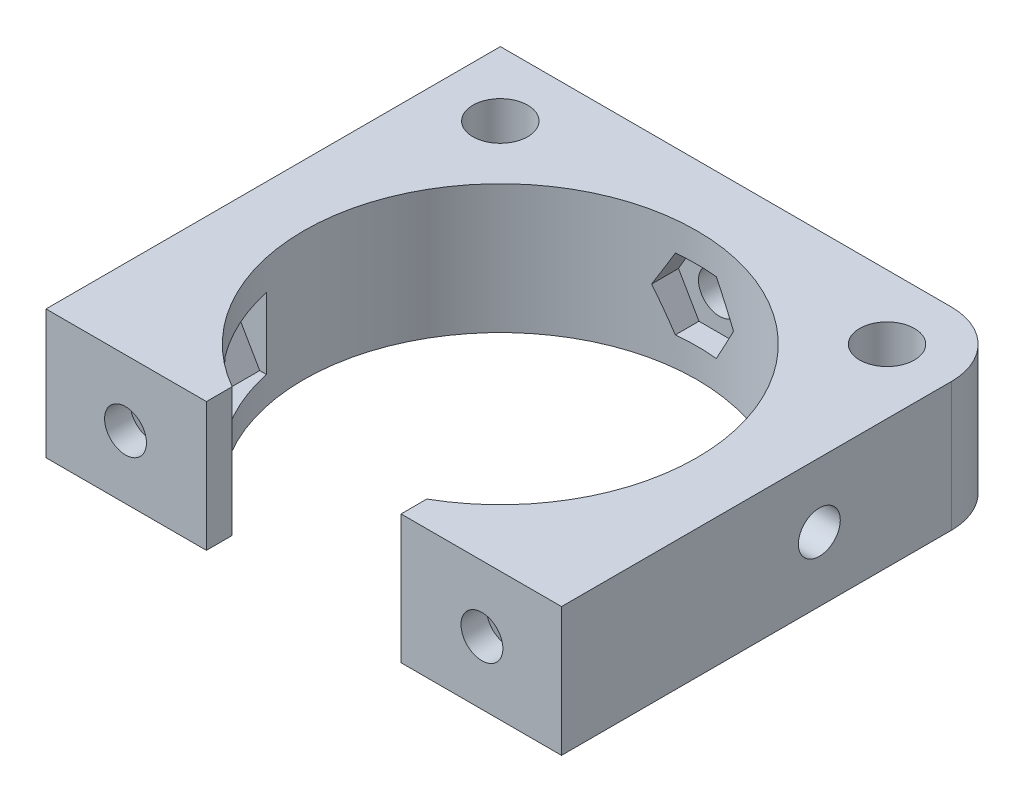
from build123d import *

# Parameters (mm, degrees)
CROQUIS1_R                              = 15.25
CROQUIS1_R_2                            = 2.125
SOPORTE_CAJA_REDUCTORA_DEPTH            = 20
CROQUIS3_R                              = 2.125
CORTAR_EXTRUIR1_DEPTH                   = 51.423828692
REDONDEO1_R                             = 5
BOSS_EXTRUDE1_DEPTH                     = 20
CUT_EXTRUDE1_REACH                      = 55.852
SKETCH2_R                               = 1.625
CUT_EXTRUDE2_DEPTH                      = 2
SKETCH4_R                               = 1.625
CUT_EXTRUDE3_DEPTH                      = 63.291652731
CUT_EXTRUDE4_START                      = -4.5
CUT_EXTRUDE4_DEPTH                      = 2
CROQUIS6_W                              = 4.75
CROQUIS6_H                              = 4.75
CORTAR_EXTRUIR17_DEPTH                  = 42.231056256
CROQUIS7_W                              = 60
CROQUIS7_H                              = 20
CORTAR_EXTRUIR18_DEPTH                  = 51.423828692
SALIENTE_EXTRUIR2_DEPTH                 = 49
SOPORTE_START                           = -15
SOPORTE_MOTOR_DEPTH                     = 15
CROQUIS12_R                             = 2.125
AGUJEROS_DE_SUJECION_A_BASE_DEPTH       = 84.087679592
TUERCA_START                            = -4
TUERCA_AGUJERO_DE_SUJECION_A_BASE_DEPTH = 10
SALIENTE_EXTRUIR4_DEPTH                 = 15
CORTAR_EXTRUIR19_DEPTH                  = 25
CROQUIS14_W                             = 50
CROQUIS14_H                             = 118
CORTAR_EXTRUIR22_DEPTH                  = 146.556045907
CROQUIS15_W                             = 10
CROQUIS15_H                             = 7
CORTAR_EXTRUIR23_DEPTH                  = 42.231056256
CORTAR_EXTRUIR24_DEPTH                  = 42.231056256
CROQUIS18_W                             = 40
CROQUIS18_H                             = 10
CORTAR_EXTRUIR25_DEPTH                  = 44.27311521
SALIENTE_EXTRUIR5_DEPTH                 = 10
CROQUIS20_R                             = 1
CORTAR_EXTRUIR26_DEPTH                  = 49.229270158
CORTAR_EXTRUIR27_REACH                  = 62.959
CORTAR_EXTRUIR27_END_RADIUS             = 15.25
CROQUIS21_R                             = 1.625
CROQUIS22_R                             = 2.125
CROQUIS22_R_2                           = 1
SALIENTE_EXTRUIR6_DEPTH                 = 10
CROQUIS23_R                             = 1.625
CORTAR_EXTRUIR28_DEPTH                  = 52.269508521
CORTAR_EXTRUIR29_START                  = -3
CORTAR_EXTRUIR29_DEPTH                  = 10
SALIENTE_EXTRUIR7_DEPTH                 = 10
CORTAR_EXTRUIR30_REACH                  = 72.235
CROQUIS27_R                             = 1.625
CORTAR_EXTRUIR31_REACH                  = 75.235
CORTAR_EXTRUIR31_START                  = -3
CORTAR_EXTRUIR32_REACH                  = 58.612
CROQUIS29_R                             = 1.625
CORTAR_EXTRUIR33_REACH                  = 61.112
CORTAR_EXTRUIR33_START                  = -2.5
CROQUIS35_W                             = 13.305418987
CROQUIS35_H                             = 6.826864192
CORTAR_EXTRUIR34_DEPTH                  = 63.931555098
CORTAR_EXTRUIR34_DEPTH_BACK             = 63.931555098
CORTAR_EXTRUIR35_START                  = -3
CORTAR_EXTRUIR35_DEPTH                  = 10
SALIENTE_EXTRUIR8_DEPTH                 = 10
SALIENTE_EXTRUIR9_DEPTH                 = 13
SALIENTE_EXTRUIR10_DEPTH                = 3
CROQUIS40_W                             = 106.583537839
CROQUIS40_H                             = 47.391515964
CORTAR_EXTRUIR36_DEPTH                  = 80.887064817
CORTAR_EXTRUIR36_DEPTH_BACK             = 80.887064817
CORTAR_EXTRUIR37_DEPTH                  = 67.2524009
CORTAR_EXTRUIR37_DEPTH_BACK             = 67.2524009
CORTAR_EXTRUIR38_DEPTH                  = 79.704784639
CORTAR_EXTRUIR38_DEPTH_BACK             = 79.704784639
SALIENTE_EXTRUIR11_DEPTH                = 10
CORTAR_EXTRUIR39_DEPTH                  = 63.9908649
CROQUIS45_W                             = 31.470301378
CROQUIS45_H                             = 10
CROQUIS45_R                             = 1.625
SALIENTE_EXTRUIR12_DEPTH                = 2.5
SALIENTE_EXTRUIR13_DEPTH                = 10
CORTAR_EXTRUIR40_START                  = -2
CROQUIS47_R                             = 1.625
CORTAR_EXTRUIR40_DEPTH                  = 10
CORTAR_EXTRUIR41_START                  = -12
CROQUIS48_R                             = 1.625
CORTAR_EXTRUIR41_DEPTH                  = 12
CORTAR_EXTRUIR42_DEPTH                  = 3
CROQUIS50_W                             = 80.415439526
CROQUIS50_H                             = 16.145703155
CORTAR_EXTRUIR43_DEPTH                  = 66.767385996
CORTAR_EXTRUIR43_DEPTH_BACK             = 66.767385996
CROQUIS51_R                             = 2.125
CORTAR_EXTRUIR44_DEPTH                  = 52.795622989
CORTAR_EXTRUIR44_DEPTH_BACK             = 52.795622989
CORTAR_EXTRUIR45_DEPTH                  = 52.795622989
CORTAR_EXTRUIR45_DEPTH_BACK             = 52.795622989
SALIENTE_EXTRUIR14_DEPTH                = 10
CORTAR_EXTRUIR46_START                  = -24.591895
CORTAR_EXTRUIR46_DEPTH                  = 17.091895
CROQUIS55_W                             = 24.668528906
CROQUIS55_H                             = 42.621944376
CORTAR_EXTRUIR47_DEPTH                  = 42.681058385
CORTAR_EXTRUIR47_DEPTH_BACK             = 42.681058385


with BuildPart() as part:
    # Croquis1 → Soporte caja reductora (new body)
    with BuildSketch(Plane(origin=(0, 0, 0), x_dir=(1, 0, 0), z_dir=(0, 1, 0))):
        Polygon((-30, -15.25), (-20, -15.25), (-20, -20), (20, -20), (20, -15.25), (30, -15.25), (30, -7.25), (20, -4.25), (20, 20), (-20, 20), (-20, -4.25), (-30, -7.25), align=None)
        with Locations(Location((0, 0, 0), (0, 0, 270))):
            Circle(CROQUIS1_R, mode=Mode.SUBTRACT)
        with Locations(Location((-15, 15, 0), (0, 0, 270))):
            Circle(CROQUIS1_R_2, mode=Mode.SUBTRACT)
        with Locations(Location((15, 15, 0), (0, 0, 270))):
            Circle(CROQUIS1_R_2, mode=Mode.SUBTRACT)
    extrude(amount=-SOPORTE_CAJA_REDUCTORA_DEPTH)

    # Croquis3 → Cortar-Extruir1 (cut, through all)
    with BuildSketch(Plane.XY.offset(15.25)):
        with Locations((-23.5, -10)):
            Circle(CROQUIS3_R)
        with Locations((23.5, -10)):
            Circle(CROQUIS3_R)
    extrude(amount=-CORTAR_EXTRUIR1_DEPTH, mode=Mode.SUBTRACT)

    # Redondeo1
    redondeo1_edges = [part.edges().sort_by_distance(p)[0] for p in [
        (-20, -10, -20),
        (20, -10, -20),
    ]]
    fillet(redondeo1_edges, radius=REDONDEO1_R)

    # Sketch1 → Boss-Extrude1 (add)
    with BuildSketch(Plane(origin=(0, 0, 0), x_dir=(1, 0, 0), z_dir=(0, 1, 0))):
        with BuildLine():
            Line((25.5, 15), (20, 15))
            ThreePointArc((20, 15), (18.535533906, 18.535533906), (15, 20))
            Line((15, 20), (30, 20))
            Line((30, 20), (30, 8))
            Line((30, 8), (25.5, 8))
            Line((25.5, 8), (25.5, 15))
        make_face()
    extrude(amount=-BOSS_EXTRUDE1_DEPTH)

    # Sketch2 → Cut-Extrude1 (cut, up to next)
    with BuildSketch(Plane(origin=(0, 0, -20), x_dir=(-1, 0, 0), z_dir=(0, 0, -1)), mode=Mode.PRIVATE) as cut_extrude1_sk1:
        with Locations((-22.75, -10)):
            Circle(SKETCH2_R)
    cut_extrude1_tool1 = extrude(cut_extrude1_sk1.sketch, amount=-CUT_EXTRUDE1_REACH, mode=Mode.PRIVATE) & part.part
    add(cut_extrude1_tool1.solids().sort_by_distance((22.75, -10, -20))[0], mode=Mode.SUBTRACT)

    # Sketch3 → Cut-Extrude2 (cut)
    with BuildSketch(Plane.XY.offset(-15)):
        Polygon((20, -11.58771324), (22.75, -13.175426481), (25.5, -11.58771324), (25.5, -8.41228676), (22.75, -6.824573519), (20, -8.41228676), align=None)
    extrude(amount=-CUT_EXTRUDE2_DEPTH, mode=Mode.SUBTRACT)

    # Sketch4 → Cut-Extrude3 (cut, through all)
    with BuildSketch(Plane.ZY.offset(-25.5)):
        with Locations((-12.25, -10)):
            Circle(SKETCH4_R)
    extrude(amount=-CUT_EXTRUDE3_DEPTH, mode=Mode.SUBTRACT)

    # Sketch5 → Cut-Extrude4 (cut)
    with BuildSketch(Plane(origin=(30, 0, 0), x_dir=(0, 0, -1), z_dir=(1, 0, 0)).offset(CUT_EXTRUDE4_START)):
        Polygon((15, -11.58771324), (15, -8.41228676), (12.25, -6.824573519), (9.5, -8.41228676), (9.5, -11.58771324), (12.25, -13.175426481), align=None)
    extrude(amount=CUT_EXTRUDE4_DEPTH, mode=Mode.SUBTRACT)

    # Croquis6 → Cortar-Extruir17 (cut, through all)
    with BuildSketch(Plane(origin=(0, 0, 0), x_dir=(1, 0, 0), z_dir=(0, 1, 0))):
        Polygon((0, -15.25), (-15.25, -15.25), (-15.25, -20), (15.25, -20), (15.25, -15.25), align=None)
        with Locations((-17.625, -17.625)):
            Rectangle(CROQUIS6_W, CROQUIS6_H)
        with BuildLine():
            ThreePointArc((0, -15.25), (-10.783378413, -10.783378413), (-15.25, 0))
            Line((-15.25, 0), (-15.25, -15.25))
            Line((-15.25, -15.25), (0, -15.25))
        make_face()
        with BuildLine():
            Line((15.25, -15.25), (15.25, 0))
            ThreePointArc((15.25, 0), (10.783378413, -10.783378413), (0, -15.25))
            Line((0, -15.25), (15.25, -15.25))
        make_face()
        with Locations((17.625, -17.625)):
            Rectangle(CROQUIS6_W, CROQUIS6_H)
    extrude(amount=-CORTAR_EXTRUIR17_DEPTH, mode=Mode.SUBTRACT)


with BuildPart() as body_2:
    # Simetría1: mirrored copy
    add(part.part.mirror(Plane.ZX))

    # Croquis8 → Saliente-Extruir2 (add)
    with BuildSketch(Plane(origin=(0, 20, 0), x_dir=(1, 0, 0), z_dir=(0, 1, 0))):
        with BuildLine():
            Line((-12.664515522, 20), (-11.040489496, 13.939052358))
            Line((-11.040489496, 13.939052358), (-10.315162126, 11.232093763))
            ThreePointArc((-10.315162126, 11.232093763), (0, 15.25), (10.315162126, 11.232093763))
            Line((10.315162126, 11.232093763), (10.817418481, 13.87928066))
            Line((10.817418481, 13.87928066), (11.978715476, 20))
            Line((11.978715476, 20), (-12.664515522, 20))
        make_face()
    extrude(amount=SALIENTE_EXTRUIR2_DEPTH)

    # Croquis9 → Soporte motor (add)
    with BuildSketch(Plane(origin=(0, 69, 0), x_dir=(1, 0, 0), z_dir=(0, 1, 0)).offset(SOPORTE_START)):
        with BuildLine():
            Line((-20, 15), (-20, -4.25))
            Line((-20, -4.25), (-30, -7.25))
            Line((-30, -7.25), (-30, -15.25))
            Line((-30, -15.25), (0, -15.25))
            Line((0, -15.25), (0, -14.75))
            ThreePointArc((0, -14.75), (-10.429825023, 10.429825023), (14.75, 0))
            Line((14.75, 0), (20, 0))
            Line((20, 0), (20, 13.936837101))
            Line((20, 13.936837101), (12.664515522, 20))
            Line((12.664515522, 20), (-15, 20))
            ThreePointArc((-15, 20), (-18.535533906, 18.535533906), (-20, 15))
        make_face()
    extrude(amount=-SOPORTE_MOTOR_DEPTH)

    # Croquis12 → Agujeros de sujecion a base (cut, through all)
    with BuildSketch(Plane.XY.offset(15.25)):
        with Locations((-23.5, 46.5)):
            Circle(CROQUIS12_R)
    extrude(amount=-AGUJEROS_DE_SUJECION_A_BASE_DEPTH, mode=Mode.SUBTRACT)

    # Croquis13 → Tuerca Agujero de sujecion a base (cut)
    with BuildSketch(Plane.XY.offset(15.25).offset(TUERCA_START)):
        Polygon((-20, 44.479274058), (-20, 48.520725942), (-23.5, 50.541451884), (-27, 48.520725942), (-27, 44.479274058), (-23.5, 42.458548116), align=None)
    extrude(amount=-TUERCA_AGUJERO_DE_SUJECION_A_BASE_DEPTH, mode=Mode.SUBTRACT)

    # Croquis10 → Saliente-Extruir4 (add)
    with BuildSketch(Plane(origin=(0, 69, 0), x_dir=(1, 0, 0), z_dir=(0, 1, 0))):
        with BuildLine():
            ThreePointArc((10.315162126, 11.232093763), (0, 15.25), (-10.315162126, 11.232093763))
            Line((-10.315162126, 11.232093763), (-10.16850369, 10.684757026))
            ThreePointArc((-10.16850369, 10.684757026), (0, 14.75), (10.16850369, 10.684757026))
            Line((10.16850369, 10.684757026), (10.315162126, 11.232093763))
        make_face()
    extrude(amount=-SALIENTE_EXTRUIR4_DEPTH)

    # Croquis11 → Cortar-Extruir19 (cut)
    with BuildSketch(Plane.XZ):
        with BuildLine():
            Line((15.25, 4.25), (20, 4.25))
            Line((20, 4.25), (21.972856468, 4.84185694))
            ThreePointArc((21.972856468, 4.84185694), (19.948931102, 10.40625523), (16.543503257, 15.25))
            Line((16.543503257, 15.25), (15.25, 15.25))
            Line((15.25, 15.25), (15.25, 4.25))
        make_face()
        with BuildLine():
            Line((21.972856468, 4.84185694), (30, 7.25))
            Line((30, 7.25), (30, 15.25))
            Line((30, 15.25), (16.543503257, 15.25))
            ThreePointArc((16.543503257, 15.25), (19.948931102, 10.40625523), (21.972856468, 4.84185694))
        make_face()
        with BuildLine():
            ThreePointArc((20, -15), (18.535533906, -18.535533906), (15, -20))
            Line((15, -20), (30, -20))
            Line((30, -20), (30, -8))
            Line((30, -8), (25.5, -8))
            Line((25.5, -8), (25.5, -15))
            Line((25.5, -15), (20, -15))
        make_face()
    extrude(amount=-CORTAR_EXTRUIR19_DEPTH, mode=Mode.SUBTRACT)

    # Simetría2: body 2 across face


with BuildPart() as part_1:
    add(part.part)

    # Croquis7 → Cortar-Extruir18 (cut, through all)
    with BuildSketch(Plane(origin=(0, 0, -20), x_dir=(-1, 0, 0), z_dir=(0, 0, -1))):
        with Locations((0, -10)):
            Rectangle(CROQUIS7_W, CROQUIS7_H)
    extrude(amount=-CORTAR_EXTRUIR18_DEPTH, mode=Mode.SUBTRACT)


with BuildPart() as body_2_1:
    add(body_2.part)
    add(body_2.part.mirror(Plane(origin=(-0.229209569, 69, -16.663998028), x_dir=(0, 0, 1), z_dir=(0, 1, 0))))

    # Croquis14 → Cortar-Extruir22 (cut, through all)
    with BuildSketch(Plane.XY.offset(15.25)):
        with Locations((-5, 79)):
            Rectangle(CROQUIS14_W, CROQUIS14_H)
    extrude(amount=-CORTAR_EXTRUIR22_DEPTH, mode=Mode.SUBTRACT)

    # Croquis15 → Cortar-Extruir23 (cut, through all)
    with BuildSketch(Plane.XZ):
        with Locations((-25, 7.75)):
            Rectangle(CROQUIS15_W, CROQUIS15_H)
    extrude(amount=-CORTAR_EXTRUIR23_DEPTH, mode=Mode.SUBTRACT)

    # Croquis16 → Cortar-Extruir24 (cut, through all)
    with BuildSketch(Plane.XZ):
        Polygon((-30, 15.25), (-15.25, 15.25), (-15.25, 12.75), (-20, 12.75), (-20, 11.25), (-30, 11.25), (-30, 12.75), align=None)
    extrude(amount=-CORTAR_EXTRUIR24_DEPTH, mode=Mode.SUBTRACT)

    # Croquis18 → Cortar-Extruir25 (cut, through all)
    with BuildSketch(Plane(origin=(0, 0, -20), x_dir=(-1, 0, 0), z_dir=(0, 0, -1))):
        with Locations((0, 5)):
            Rectangle(CROQUIS18_W, CROQUIS18_H)
    extrude(amount=-CORTAR_EXTRUIR25_DEPTH, mode=Mode.SUBTRACT)

    # Croquis19 → Saliente-Extruir5 (add)
    with BuildSketch(Plane(origin=(0, 20, 0), x_dir=(1, 0, 0), z_dir=(0, 1, 0))):
        Polygon((-20, -12.75), (-34, -12.75), (-34, -7.75), (-24, -7.75), (-20, -3.75), align=None)
    extrude(amount=-SALIENTE_EXTRUIR5_DEPTH)

    # Croquis20 → Cortar-Extruir26 (cut, through all)
    with BuildSketch(Plane(origin=(0, 0, 7.75), x_dir=(-1, 0, 0), z_dir=(0, 0, -1))):
        with Locations((29, 15)):
            Circle(CROQUIS20_R)
    extrude(amount=-CORTAR_EXTRUIR26_DEPTH, mode=Mode.SUBTRACT)

    # Cortar-Extruir27: up to this cylinder (the profile starts outside it)
    cortar_extruir27_end = Plane(origin=(0, 15, 0), z_dir=(0, -1, 0)) * Cylinder(CORTAR_EXTRUIR27_END_RADIUS, 157.418, mode=Mode.PRIVATE)
    # Croquis21 → Cortar-Extruir27 (cut, up to the surface)
    with BuildSketch(Plane(origin=(20, 0, 0), x_dir=(0, 0, -1), z_dir=(1, 0, 0)), mode=Mode.PRIVATE) as cortar_extruir27_sk1:
        with Locations((4.75, 15)):
            Circle(CROQUIS21_R)
    cortar_extruir27_tool1 = extrude(cortar_extruir27_sk1.sketch, amount=-CORTAR_EXTRUIR27_REACH, mode=Mode.PRIVATE) - cortar_extruir27_end
    add(cortar_extruir27_tool1.solids().sort_by_distance((20, 15, -4.75))[0], mode=Mode.SUBTRACT)

    # Croquis22 → Saliente-Extruir6 (add)
    with BuildSketch(Plane.XZ.offset(-10)):
        with Locations((-15, -15)):
            Circle(CROQUIS22_R)
        with Locations(Location((-15, -15, 0), (0, 0, 270))):
            Circle(CROQUIS22_R_2, mode=Mode.SUBTRACT)
        with Locations((15, -15)):
            Circle(CROQUIS22_R)
        with Locations(Location((15, -15, 0), (0, 0, 270))):
            Circle(CROQUIS22_R_2, mode=Mode.SUBTRACT)
    extrude(amount=-SALIENTE_EXTRUIR6_DEPTH)

    # Croquis23 → Cortar-Extruir28 (cut, through all)
    with BuildSketch(Plane(origin=(0, 0, -20), x_dir=(-1, 0, 0), z_dir=(0, 0, -1))):
        with Locations((0, 15)):
            Circle(CROQUIS23_R)
    extrude(amount=-CORTAR_EXTRUIR28_DEPTH, mode=Mode.SUBTRACT)

    # Croquis24 → Cortar-Extruir29 (cut)
    with BuildSketch(Plane(origin=(0, 0, -20), x_dir=(-1, 0, 0), z_dir=(0, 0, -1)).offset(CORTAR_EXTRUIR29_START)):
        Polygon((1.58771324, 12.25), (3.175426481, 15), (1.58771324, 17.75), (-1.58771324, 17.75), (-3.175426481, 15), (-1.58771324, 12.25), align=None)
    extrude(amount=-CORTAR_EXTRUIR29_DEPTH, mode=Mode.SUBTRACT)

    # Croquis26 → Saliente-Extruir7 (add)
    with BuildSketch(Plane.XZ.offset(-10)):
        Polygon((-34, 7.75), (-34, 12.75), (-58.825, 12.75), (-39.160527763, -4.104491148), (-20, -4.104491148), (-20, -0.104491148), (-35.732113118, -0.104491148), (-29, 7.75), align=None)
        Polygon((-34.268209086, 7.75), (-39.594516123, 1.535690951), (-46.844874897, 7.75), align=None, mode=Mode.SUBTRACT)
    extrude(amount=-SALIENTE_EXTRUIR7_DEPTH)

    # Croquis27 → Cortar-Extruir30 (cut, up to next)
    with BuildSketch(Plane.XY.offset(12.75), mode=Mode.PRIVATE) as cortar_extruir30_sk1:
        with Locations((-40.544874897, 15)):
            Circle(CROQUIS27_R)
    cortar_extruir30_tool1 = extrude(cortar_extruir30_sk1.sketch, amount=-CORTAR_EXTRUIR30_REACH, mode=Mode.PRIVATE) & body_2_1.part
    # Croquis27 → Cortar-Extruir30 (cut, up to next)
    with BuildSketch(Plane.XY.offset(12.75), mode=Mode.PRIVATE) as cortar_extruir30_sk2:
        with Locations((-29, 15)):
            Circle(CROQUIS27_R)
    cortar_extruir30_tool2 = extrude(cortar_extruir30_sk2.sketch, amount=-CORTAR_EXTRUIR30_REACH, mode=Mode.PRIVATE) & body_2_1.part
    add(cortar_extruir30_tool1.solids().sort_by_distance((-40.544875, 15, 12.75))[0], mode=Mode.SUBTRACT)
    add(cortar_extruir30_tool2.solids().sort_by_distance((-29, 15, 12.75))[0], mode=Mode.SUBTRACT)

    # Croquis28 → Cortar-Extruir31 (cut, up to next)
    with BuildSketch(Plane.XY.offset(12.75).offset(CORTAR_EXTRUIR31_START), mode=Mode.PRIVATE) as cortar_extruir31_sk1:
        Polygon((-38.957161657, 12.25), (-37.369448416, 15), (-38.957161657, 17.75), (-42.132588137, 17.75), (-43.720301378, 15), (-42.132588137, 12.25), align=None)
    cortar_extruir31_tool1 = extrude(cortar_extruir31_sk1.sketch, amount=-CORTAR_EXTRUIR31_REACH, mode=Mode.PRIVATE) & body_2_1.part
    # Croquis28 → Cortar-Extruir31 (cut, up to next)
    with BuildSketch(Plane.XY.offset(12.75).offset(CORTAR_EXTRUIR31_START), mode=Mode.PRIVATE) as cortar_extruir31_sk2:
        Polygon((-27.41228676, 12.25), (-25.824573519, 15), (-27.41228676, 17.75), (-30.58771324, 17.75), (-32.175426481, 15), (-30.58771324, 12.25), align=None)
    cortar_extruir31_tool2 = extrude(cortar_extruir31_sk2.sketch, amount=-CORTAR_EXTRUIR31_REACH, mode=Mode.PRIVATE) & body_2_1.part
    add(cortar_extruir31_tool1.solids().sort_by_distance((-40.544875, 15, 9.75))[0], mode=Mode.SUBTRACT)
    add(cortar_extruir31_tool2.solids().sort_by_distance((-29, 15, 9.75))[0], mode=Mode.SUBTRACT)

    # Croquis29 → Cortar-Extruir32 (cut, up to next)
    with BuildSketch(Plane(origin=(-18.612848159, 0, -21.715982563), x_dir=(-0.7592713073348843, 0, 0.6507742172658468), z_dir=(-0.6507742172658468, 0, -0.7592713073348843)), mode=Mode.PRIVATE) as cortar_extruir32_sk1:
        with Locations((33.812368097, 15)):
            Circle(CROQUIS29_R)
    cortar_extruir32_tool1 = extrude(cortar_extruir32_sk1.sketch, amount=-CORTAR_EXTRUIR32_REACH, mode=Mode.PRIVATE) & body_2_1.part
    add(cortar_extruir32_tool1.solids().sort_by_distance((-44.285609, 15, 0.288235))[0], mode=Mode.SUBTRACT)

    # Croquis31 → Cortar-Extruir33 (cut, up to next)
    with BuildSketch(Plane(origin=(-18.612848159, 0, -21.715982563), x_dir=(-0.7592713073348843, 0, 0.6507742172658468), z_dir=(-0.6507742172658468, 0, -0.7592713073348843)).offset(CORTAR_EXTRUIR33_START), mode=Mode.PRIVATE) as cortar_extruir33_sk1:
        Polygon((36.562368097, 16.58771324), (33.812368097, 18.175426481), (31.062368097, 16.58771324), (31.062368097, 13.41228676), (33.812368097, 11.824573519), (36.562368097, 13.41228676), align=None)
    cortar_extruir33_tool1 = extrude(cortar_extruir33_sk1.sketch, amount=-CORTAR_EXTRUIR33_REACH, mode=Mode.PRIVATE) & body_2_1.part
    add(cortar_extruir33_tool1.solids().sort_by_distance((-42.658674, 15, 2.186413))[0], mode=Mode.SUBTRACT)

    # Croquis35 → Cortar-Extruir34 (cut, two sides)
    with BuildSketch(Plane(origin=(0, 20, 0), x_dir=(1, 0, 0), z_dir=(0, 1, 0))) as cortar_extruir34_sk:
        with Locations((17.04227466, -3.413432096)):
            Rectangle(CROQUIS35_W, CROQUIS35_H)
    extrude(amount=CORTAR_EXTRUIR34_DEPTH, mode=Mode.SUBTRACT)
    extrude(cortar_extruir34_sk.sketch, amount=-CORTAR_EXTRUIR34_DEPTH_BACK, mode=Mode.SUBTRACT)

    # Croquis36 → Cortar-Extruir35 (cut)
    with BuildSketch(Plane(origin=(20, 0, 0), x_dir=(0, 0, -1), z_dir=(1, 0, 0)).offset(CORTAR_EXTRUIR35_START)):
        Polygon((7.5, 16.58771324), (4.75, 18.175426481), (2, 16.58771324), (2, 13.41228676), (4.75, 11.824573519), (7.5, 13.41228676), align=None)
    extrude(amount=-CORTAR_EXTRUIR35_DEPTH, mode=Mode.SUBTRACT)

    # Croquis37 → Saliente-Extruir8 (add)
    with BuildSketch(Plane.XZ.offset(-10)):
        Polygon((-39.160527763, -4.104491148), (-20.614919368, -20), (-15, -20), (-19.558128305, -15.637570403), (-33.014002756, -4.104491148), align=None)
    extrude(amount=-SALIENTE_EXTRUIR8_DEPTH)

    # Croquis38 → Saliente-Extruir9 (add)
    with BuildSketch(Plane.XZ.offset(-10)):
        Polygon((-58.825, 12.75), (-38.825, 12.75), (-38.825, 9.75), (-55.324839942, 9.75), align=None)
    extrude(amount=SALIENTE_EXTRUIR9_DEPTH)

    # Croquis39 → Saliente-Extruir10 (add)
    with BuildSketch(Plane.XZ.offset(-10)):
        Polygon((-38.825, 9.75), (-38.825, 7.75), (-38.825, 5.75), (-50.657959865, 5.75), (-52.991399903, 7.75), (-55.324839942, 9.75), align=None)
    extrude(amount=SALIENTE_EXTRUIR10_DEPTH)

    # Simetría3: body 2 across face


with BuildPart() as body_2_2:
    add(body_2_1.part)
    add(body_2_1.part.mirror(Plane(origin=(-18.003999227, 20, -4.220503046), x_dir=(0, 0, 1), z_dir=(0, 1, 0))))

    # Croquis40 → Cortar-Extruir36 (cut, two sides)
    with BuildSketch(Plane(origin=(0, 0, -20), x_dir=(-1, 0, 0), z_dir=(0, 0, -1))) as cortar_extruir36_sk:
        with Locations((22.395502026, -3.695757982)):
            Rectangle(CROQUIS40_W, CROQUIS40_H)
    extrude(amount=CORTAR_EXTRUIR36_DEPTH, mode=Mode.SUBTRACT)
    extrude(cortar_extruir36_sk.sketch, amount=-CORTAR_EXTRUIR36_DEPTH_BACK, mode=Mode.SUBTRACT)

    # Croquis41 → Cortar-Extruir37 (cut, two sides)
    with BuildSketch(Plane.XZ.offset(-20)) as cortar_extruir37_sk:
        Polygon((-19.992980133, -22.302484261), (-20, 3.75), (-24, 7.75), (-56.035110209, 7.75), align=None)
    extrude(amount=CORTAR_EXTRUIR37_DEPTH, mode=Mode.SUBTRACT)
    extrude(cortar_extruir37_sk.sketch, amount=-CORTAR_EXTRUIR37_DEPTH_BACK, mode=Mode.SUBTRACT)

    # Croquis42 → Cortar-Extruir38 (cut, two sides)
    with BuildSketch(Plane(origin=(0, 0, 9.75), x_dir=(-1, 0, 0), z_dir=(0, 0, -1))) as cortar_extruir38_sk:
        Polygon((46.720301378, 20), (46.720301378, 30), (38.825, 30), (33.492952769, 43.760628779), (49.525340398, 48.951442806), (67.200390695, 42.512205152), (65.906601328, 20), (51.713995885, 13.864168239), align=None)
    extrude(amount=CORTAR_EXTRUIR38_DEPTH, mode=Mode.SUBTRACT)
    extrude(cortar_extruir38_sk.sketch, amount=-CORTAR_EXTRUIR38_DEPTH_BACK, mode=Mode.SUBTRACT)

    # Croquis43 → Saliente-Extruir11 (add)
    with BuildSketch(Plane.XZ.offset(-20)):
        Polygon((-19.993600539, -20), (-46.720301378, 7.75), (-43.839252857, 10.524807997), (-17.112552018, -17.225192003), align=None)
    extrude(amount=-SALIENTE_EXTRUIR11_DEPTH)

    # Croquis44 → Cortar-Extruir39 (cut, through all)
    with BuildSketch(Plane(origin=(0, 0, 9.75), x_dir=(-1, 0, 0), z_dir=(0, 0, -1))):
        Polygon((38.957161657, 27.75), (37.369448416, 25), (38.957161657, 22.25), (42.132588137, 22.25), (43.720301378, 25), (42.132588137, 27.75), align=None)
    extrude(amount=CORTAR_EXTRUIR39_DEPTH, mode=Mode.SUBTRACT)

    # Croquis45 → Saliente-Extruir12 (add)
    with BuildSketch(Plane.XY.offset(12.75)):
        with Locations((-30.985150689, 25)):
            Rectangle(CROQUIS45_W, CROQUIS45_H)
        with Locations((-40.544874897, 25)):
            Circle(CROQUIS45_R, mode=Mode.SUBTRACT)
        with Locations((-29, 25)):
            Circle(CROQUIS45_R, mode=Mode.SUBTRACT)
    extrude(amount=SALIENTE_EXTRUIR12_DEPTH)

    # Croquis46 → Saliente-Extruir13 (add)
    with BuildSketch(Plane.XZ.offset(-20)):
        with BuildLine():
            Line((15.25, 0), (20, 0))
            Line((20, 0), (20, 15.25))
            Line((20, 15.25), (7.549834435, 15.25))
            Line((7.549834435, 15.25), (7.549834435, 13.25))
            ThreePointArc((7.549834435, 13.25), (13.185171124, 7.662490615), (15.25, 0))
        make_face()
        with BuildLine():
            Line((-15.25, 0), (-15.25, 15.25))
            Line((-15.25, 15.25), (-7.549834435, 15.25))
            Line((-7.549834435, 15.25), (-7.549834435, 13.25))
            ThreePointArc((-7.549834435, 13.25), (-13.185171124, 7.662490615), (-15.25, 0))
        make_face()
    extrude(amount=-SALIENTE_EXTRUIR13_DEPTH)

    # Croquis47 → Cortar-Extruir40 (cut)
    with BuildSketch(Plane.XY.offset(15.25).offset(CORTAR_EXTRUIR40_START)):
        Polygon((15.41228676, 22.352505966), (17, 25.102505966), (15.41228676, 27.852505966), (12.236860279, 27.852505966), (10.649147039, 25.102505966), (12.236860279, 22.352505966), align=None)
        with Locations((13.824573519, 25.102505966)):
            Circle(CROQUIS47_R, mode=Mode.SUBTRACT)
        Polygon((-12.236860279, 22.352505966), (-15.41228676, 22.352505966), (-17, 25.102505966), (-15.41228676, 27.852505966), (-12.236860279, 27.852505966), (-10.649147039, 25.102505966), align=None)
        with Locations(Location((-13.824573519, 25.102505966, 0), (0, 0, 131.421584744))):
            Circle(CROQUIS47_R, mode=Mode.SUBTRACT)
    extrude(amount=-CORTAR_EXTRUIR40_DEPTH, mode=Mode.SUBTRACT)

    # Croquis48 → Cortar-Extruir41 (cut)
    with BuildSketch(Plane.XY.offset(15.25).offset(CORTAR_EXTRUIR41_START)):
        with Locations((13.824573519, 25.102505966)):
            Circle(CROQUIS48_R)
        with Locations((-13.824573519, 25.102505966)):
            Circle(CROQUIS48_R)
    extrude(amount=CORTAR_EXTRUIR41_DEPTH, mode=Mode.SUBTRACT)

    # Croquis49 → Cortar-Extruir42 (cut)
    with BuildSketch(Plane(origin=(0, 30, 0), x_dir=(1, 0, 0), z_dir=(0, 1, 0))):
        Polygon((-12.979274058, 11.5), (-10.958548116, 15), (-12.979274058, 18.5), (-17.020725942, 18.5), (-19.041451884, 15), (-17.020725942, 11.5), align=None)
        Polygon((17.020725942, 11.5), (19.041451884, 15), (17.020725942, 18.5), (12.979274058, 18.5), (10.958548116, 15), (12.979274058, 11.5), align=None)
    extrude(amount=-CORTAR_EXTRUIR42_DEPTH, mode=Mode.SUBTRACT)

    # Simetría4: body 2 across plane


with BuildPart() as body_2_3:
    add(body_2_2.part)
    add(body_2_2.part.mirror(Plane(origin=(30.896266894, 20, 12.75), x_dir=(0, 0, 1), z_dir=(0, 1, 0))))

    # Croquis50 → Cortar-Extruir43 (cut, two sides)
    with BuildSketch(Plane(origin=(0, 0, -20), x_dir=(-1, 0, 0), z_dir=(0, 0, -1))) as cortar_extruir43_sk:
        with Locations((12.268612219, 28.072851577)):
            Rectangle(CROQUIS50_W, CROQUIS50_H)
    extrude(amount=CORTAR_EXTRUIR43_DEPTH, mode=Mode.SUBTRACT)
    extrude(cortar_extruir43_sk.sketch, amount=-CORTAR_EXTRUIR43_DEPTH_BACK, mode=Mode.SUBTRACT)

    # Croquis51 → Cortar-Extruir44 (cut, two sides)
    with BuildSketch(Plane.XZ.offset(-10)) as cortar_extruir44_sk:
        with Locations(Location((-15, -15, 0), (0, 0, 270))):
            Circle(CROQUIS51_R)
        with Locations(Location((15, -15, 0), (0, 0, 270))):
            Circle(CROQUIS51_R)
    extrude(amount=CORTAR_EXTRUIR44_DEPTH, mode=Mode.SUBTRACT)
    extrude(cortar_extruir44_sk.sketch, amount=-CORTAR_EXTRUIR44_DEPTH_BACK, mode=Mode.SUBTRACT)

    # Croquis52 → Cortar-Extruir45 (cut, two sides)
    with BuildSketch(Plane.XZ.offset(-10)) as cortar_extruir45_sk:
        Polygon((-35.175426481, 15.25), (-35.175426481, 7.75), (-19.995154673, -14.232221634), (-19.993600539, -20), (-54.542897094, 5.516026969), (-50.455586096, 20.949060485), align=None)
    extrude(amount=CORTAR_EXTRUIR45_DEPTH, mode=Mode.SUBTRACT)
    extrude(cortar_extruir45_sk.sketch, amount=-CORTAR_EXTRUIR45_DEPTH_BACK, mode=Mode.SUBTRACT)

    # Croquis53 → Saliente-Extruir14 (add)
    with BuildSketch(Plane.XZ.offset(-10)):
        Polygon((-35.175426481, 7.75), (-19.993600539, -20), (-20, 3.75), (-24, 7.75), align=None)
    extrude(amount=-SALIENTE_EXTRUIR14_DEPTH)

    # Croquis54 → Cortar-Extruir46 (cut)
    with BuildSketch(Plane.XY.offset(15.25).offset(CORTAR_EXTRUIR46_START)):
        Polygon((-27.41228676, 17.75), (-30.58771324, 17.75), (-32.175426481, 15), (-30.58771324, 12.25), (-27.41228676, 12.25), (-25.824573519, 15), align=None)
    extrude(amount=CORTAR_EXTRUIR46_DEPTH, mode=Mode.SUBTRACT)

    # Croquis55 → Cortar-Extruir47 (cut, two sides)
    with BuildSketch(Plane(origin=(0, 20, 0), x_dir=(1, 0, 0), z_dir=(0, 1, 0))) as cortar_extruir47_sk:
        with Locations((-32.327864992, -1.310972188)):
            Rectangle(CROQUIS55_W, CROQUIS55_H)
    extrude(amount=CORTAR_EXTRUIR47_DEPTH, mode=Mode.SUBTRACT)
    extrude(cortar_extruir47_sk.sketch, amount=-CORTAR_EXTRUIR47_DEPTH_BACK, mode=Mode.SUBTRACT)


solid = body_2_3.part
